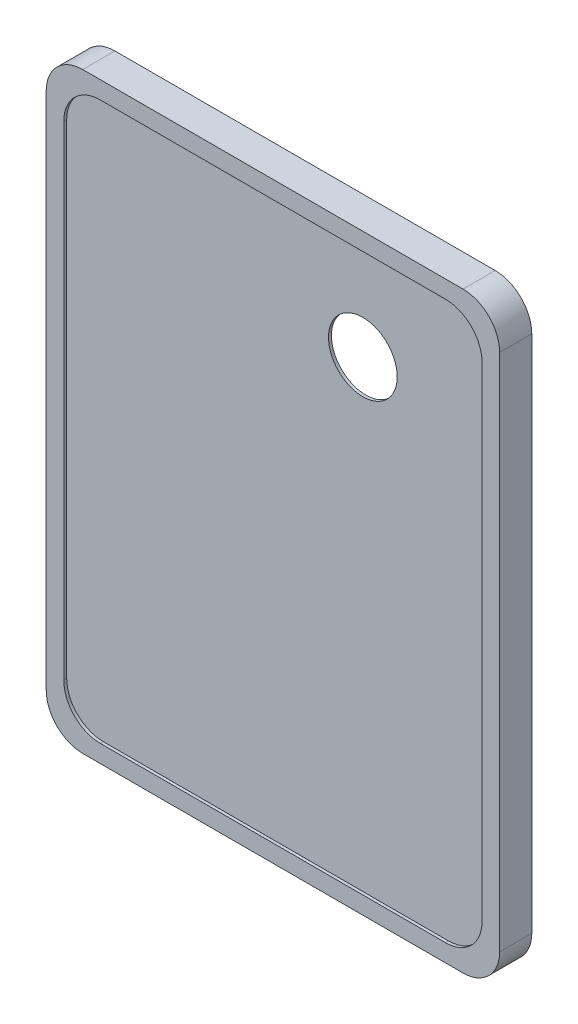
from build123d import *

# Parameters (mm, degrees)
BOSS_EXTRUDE1_DEPTH = 5.588
CUT_EXTRUDE1_DEPTH  = 0.508
SHELL2_T            = -0.508
SKETCH3_R           = 5.969
CUT_EXTRUDE2_DEPTH  = 0.508
SKETCH5_W           = 2.54
SKETCH5_H           = 0.508
BOSS_EXTRUDE2_DEPTH = 76.708
SKETCH7_R           = 1.27
BOSS_EXTRUDE3_DEPTH = 76.708
CUT_EXTRUDE3_DEPTH  = 79.74
SKETCH9_R           = 1.016
CUT_EXTRUDE4_DEPTH  = 79.74
SKETCH10_W          = 7.112
SKETCH10_H          = 2.032
SKETCH10_W_2        = 12.7
CUT_EXTRUDE5_DEPTH  = 9.382
SKETCH11_W          = 10.616681579
SKETCH11_H          = 2.54
SKETCH11_W_2        = 10.870681579
CUT_EXTRUDE6_DEPTH  = 3.5400001
SKETCH12_W          = 7.112
SKETCH12_H          = 2.54
CUT_EXTRUDE7_DEPTH  = 3.54


with BuildPart() as part:
    # Sketch1 → Boss-Extrude1 (new body)
    with BuildSketch(Plane.XY):
        with BuildLine():
            Line((-33.02, 51.435), (33.02, 51.435))
            ThreePointArc((33.02, 51.435), (37.510128061, 49.575128061), (39.37, 45.085))
            Line((39.37, 45.085), (39.37, -45.085))
            ThreePointArc((39.37, -45.085), (37.510128061, -49.575128061), (33.02, -51.435))
            Line((33.02, -51.435), (-33.02, -51.435))
            ThreePointArc((-33.02, -51.435), (-37.510128061, -49.575128061), (-39.37, -45.085))
            Line((-39.37, -45.085), (-39.37, 45.085))
            ThreePointArc((-39.37, 45.085), (-37.510128061, 49.575128061), (-33.02, 51.435))
        make_face()
    extrude(amount=BOSS_EXTRUDE1_DEPTH)

    # Sketch2 → Cut-Extrude1 (cut)
    with BuildSketch(Plane.XY.offset(5.588)):
        with BuildLine():
            Line((-29.972, -48.387), (29.972, -48.387))
            ThreePointArc((29.972, -48.387), (34.462128061, -46.527128061), (36.322, -42.037))
            Line((36.322, -42.037), (36.322, 42.037))
            ThreePointArc((36.322, 42.037), (34.462128061, 46.527128061), (29.972, 48.387))
            Line((29.972, 48.387), (-29.972, 48.387))
            ThreePointArc((-29.972, 48.387), (-34.462128061, 46.527128061), (-36.322, 42.037))
            Line((-36.322, 42.037), (-36.322, -42.037))
            ThreePointArc((-36.322, -42.037), (-34.462128061, -46.527128061), (-29.972, -48.387))
        make_face()
    extrude(amount=-CUT_EXTRUDE1_DEPTH, mode=Mode.SUBTRACT)

    # Shell2
    shell2_openings = [part.faces().sort_by_distance(p)[0] for p in [
        (0, 0, 0),
    ]]
    offset(amount=SHELL2_T, openings=shell2_openings, kind=Kind.INTERSECTION)

    # Sketch3 → Cut-Extrude2 (cut)
    with BuildSketch(Plane.XY.offset(5.08)):
        with Locations((15.113, 32.004)):
            Circle(SKETCH3_R)
    extrude(amount=-CUT_EXTRUDE2_DEPTH, mode=Mode.SUBTRACT)

    # Sketch5 → Boss-Extrude2 (add)
    with BuildSketch(Plane(origin=(39.37, 0, 0), x_dir=(0, 0, -1), z_dir=(1, 0, 0))):
        with Locations((1.27, -51.181)):
            Rectangle(SKETCH5_W, SKETCH5_H)
    extrude(amount=-BOSS_EXTRUDE2_DEPTH)

    # Sketch7 → Boss-Extrude3 (add)
    with BuildSketch(Plane(origin=(39.37, 0, 0), x_dir=(0, 0, -1), z_dir=(1, 0, 0))):
        with Locations((1.524, -52.197)):
            Circle(SKETCH7_R)
    extrude(amount=-BOSS_EXTRUDE3_DEPTH)

    # Sketch8 → Cut-Extrude3 (cut, through all)
    with BuildSketch(Plane(origin=(39.37, 0, 0), x_dir=(0, 0, -1), z_dir=(1, 0, 0))):
        with BuildLine():
            Line((2.54, -50.927), (1.524, -50.927))
            ThreePointArc((1.524, -50.927), (2.091961266, -51.061077467), (2.54, -51.435))
            Line((2.54, -51.435), (2.54, -50.927))
        make_face()
    extrude(amount=-CUT_EXTRUDE3_DEPTH, mode=Mode.SUBTRACT)

    # Sketch9 → Cut-Extrude4 (cut, through all)
    with BuildSketch(Plane(origin=(39.37, 0, 0), x_dir=(0, 0, -1), z_dir=(1, 0, 0))):
        with Locations((1.524, -52.197)):
            Circle(SKETCH9_R)
    extrude(amount=-CUT_EXTRUDE4_DEPTH, mode=Mode.SUBTRACT)

    # Sketch10 → Cut-Extrude5 (cut, through all)
    with BuildSketch(Plane.XY.offset(5.588)):
        with Locations((-13.97, -52.451)):
            Rectangle(SKETCH10_W, SKETCH10_H)
        with Locations((0.254, -52.451)):
            Rectangle(SKETCH10_W, SKETCH10_H)
        with Locations((14.478, -52.451)):
            Rectangle(SKETCH10_W, SKETCH10_H)
        Polygon((39.37, -54.461005148), (39.37, -51.435), (33.02, -51.435), (24.892, -51.435), (24.892, -54.461005148), align=None)
        with Locations((-30.988, -52.451)):
            Rectangle(SKETCH10_W_2, SKETCH10_H)
        with BuildLine():
            Line((-35.508681579, -50.927), (-37.338, -50.927))
            Line((-37.338, -50.927), (-37.338, -51.435))
            Line((-37.338, -51.435), (-33.02, -51.435))
            ThreePointArc((-33.02, -51.435), (-34.29, -51.306703947), (-35.508681579, -50.927))
        make_face()
        with BuildLine():
            Line((39.37, -50.927), (35.508681579, -50.927))
            ThreePointArc((35.508681579, -50.927), (34.29, -51.306703947), (33.02, -51.435))
            Line((33.02, -51.435), (39.37, -51.435))
            Line((39.37, -51.435), (39.37, -50.927))
        make_face()
    extrude(amount=-CUT_EXTRUDE5_DEPTH, mode=Mode.SUBTRACT)

    # Sketch11 → Cut-Extrude6 (cut, through all)
    with BuildSketch(Plane(origin=(0, -50.927, 0), x_dir=(1, 0, 0), z_dir=(0, 1, 0))):
        with Locations((30.20034079, 1.27)):
            Rectangle(SKETCH11_W, SKETCH11_H)
        with Locations((-30.07334079, 1.27)):
            Rectangle(SKETCH11_W_2, SKETCH11_H)
    extrude(amount=-CUT_EXTRUDE6_DEPTH, mode=Mode.SUBTRACT)

    # Sketch12 → Cut-Extrude7 (cut, through all)
    with BuildSketch(Plane(origin=(0, -50.927, 0), x_dir=(1, 0, 0), z_dir=(0, 1, 0))):
        with Locations((14.478, 1.27)):
            Rectangle(SKETCH12_W, SKETCH12_H)
        with Locations((0.254, 1.27)):
            Rectangle(SKETCH12_W, SKETCH12_H)
        with Locations((-13.97, 1.27)):
            Rectangle(SKETCH12_W, SKETCH12_H)
    extrude(amount=-CUT_EXTRUDE7_DEPTH, mode=Mode.SUBTRACT)


solid = part.part
